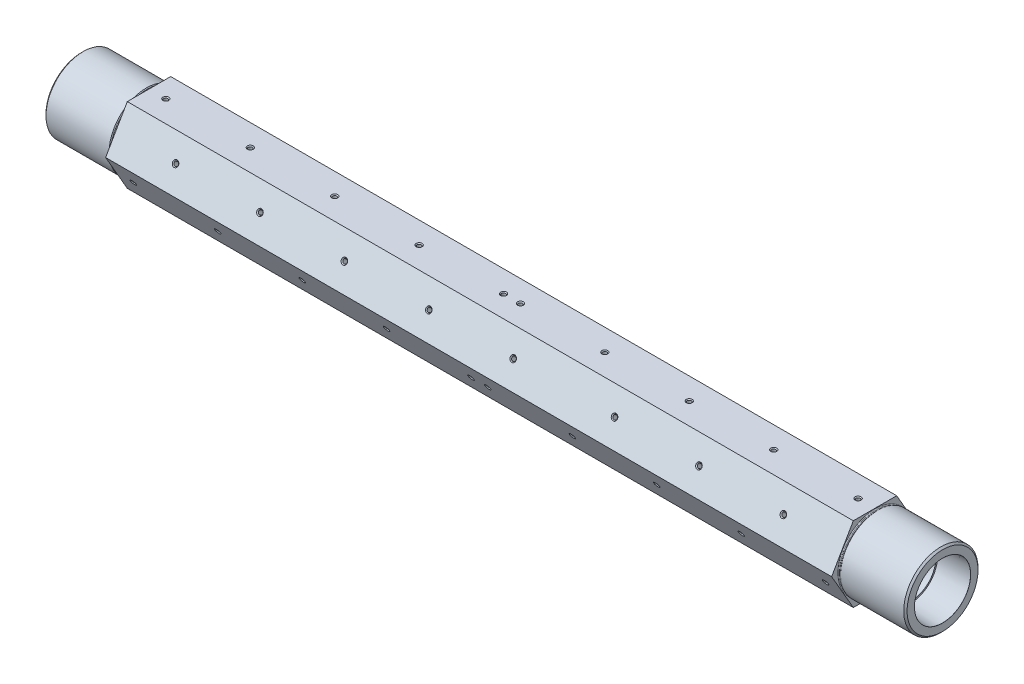
from build123d import *

# Parameters (mm, degrees)
EXTRUDE_1_DEPTH             = 430
HOLE_WIZARD_2_5_2_5_1_D     = 2.5
HOLE_WIZARD_2_5_2_5_1_DEPTH = 7
HOLE_WIZARD_2_5_2_5_1_TIP   = 0.751075774
HOLE_WIZARD_2_5_2_5_2_D     = 2.5
HOLE_WIZARD_2_5_2_5_2_DEPTH = 7
HOLE_WIZARD_2_5_2_5_2_TIP   = 0.751075774
HOLE_WIZARD_2_5_2_5_3_D     = 2.5
HOLE_WIZARD_2_5_2_5_3_DEPTH = 7
HOLE_WIZARD_2_5_2_5_3_TIP   = 0.751075774
HOLE_WIZARD_2_5_2_5_4_D     = 2.5
HOLE_WIZARD_2_5_2_5_4_DEPTH = 7
HOLE_WIZARD_2_5_2_5_4_TIP   = 0.751075774
HOLE_WIZARD_2_5_2_5_5_D     = 2.5
HOLE_WIZARD_2_5_2_5_5_DEPTH = 7
HOLE_WIZARD_2_5_2_5_5_TIP   = 0.751075774
HOLE_WIZARD_2_5_2_5_6_D     = 2.5
HOLE_WIZARD_2_5_2_5_6_DEPTH = 7
HOLE_WIZARD_2_5_2_5_6_TIP   = 0.751075774
CHAMFER_1_SIZE              = 0.5
CHAMFER_2_SIZE              = 1
CHAMFER_3_SIZE2             = 0.025012178
CHAMFER_3_SIZE              = 0.024219584
CHAMFER_3_EDGE_2_SIZE2      = 0.025012178
CHAMFER_3_EDGE_2_SIZE       = 0.024219584
FILLET_1_R                  = 0.3
FILLET_2_R                  = 0.5


with BuildPart() as part:
    # Эскиз1 → Бобышка-Вытянуть1 (new body)
    with BuildSketch(Plane(origin=(470, 0, 0), x_dir=(0, 0, -1), z_dir=(1, 0, 0))):
        Polygon((-12.846043489, -22.25), (12.846043489, -22.25), (25.692086979, 0), (12.846043489, 22.25), (-12.846043489, 22.25), (-25.692086979, 0), align=None)
    extrude(amount=-EXTRUDE_1_DEPTH)

    # Эскиз2 → Повернуть1 (revolve)
    with BuildSketch(Plane.XY):
        Polygon((0, 22), (0, 0), (40, 0), (40, 21.5), (38.875735931, 21.5), (38.375735931, 22), align=None)
    revolve(axis=Axis((0, 0, 0), (1, 0, 0)))

    # Эскиз3 → Повернуть2 (revolve)
    with BuildSketch(Plane.XY):
        Polygon((470, 21.5), (470, 0), (510, 0), (510, 22), (471.624264069, 22), (471.124264069, 21.5), align=None)
    revolve(axis=Axis((470, 0, 0), (1, 0, 0)))

    # Эскиз4 → Вырез-Повернуть1 (revolve, cut)
    with BuildSketch(Plane.XY):
        Polygon((0, 16.625280416), (0, 0), (510, 0), (510, 16.625280416), (491, 16.032164615), (491, 15.1455), (474, 15.1455), (474, 12), (36, 12), (36, 15.145), (19, 15.145), (19, 16.032164615), align=None)
    revolve(axis=Axis((0, 0, 0), (1, 0, 0)), mode=Mode.SUBTRACT)

    # Диаметр отверстия Ø2.5 (2.5)1
    with Locations(Plane(origin=(0, 11.125, 19.269065234), x_dir=(1, 0, 0), z_dir=(0, 0.5, 0.866025404))):
        with Locations((75, 0), (125, 0), (175, 0), (225, 0), (275, 0), (335, 0), (385, 0), (435, 0)):
            Hole(HOLE_WIZARD_2_5_2_5_1_D / 2, depth=HOLE_WIZARD_2_5_2_5_1_DEPTH)
            with Locations((0, 0, -(HOLE_WIZARD_2_5_2_5_1_DEPTH + HOLE_WIZARD_2_5_2_5_1_TIP / 2))):  # 118° drill point
                Cone(0, HOLE_WIZARD_2_5_2_5_1_D / 2, HOLE_WIZARD_2_5_2_5_1_TIP, mode=Mode.SUBTRACT)

    # Диаметр отверстия Ø2.5 (2.5)2
    with Locations(Plane(origin=(0, -22.25, 0), x_dir=(-1, 0, 0), z_dir=(0, -1, 0))):
        with Locations((-75, 0), (-125, 0), (-175, 0), (-225, 0), (-275, 0), (-335, 0), (-385, 0), (-435, 0)):
            Hole(HOLE_WIZARD_2_5_2_5_2_D / 2, depth=HOLE_WIZARD_2_5_2_5_2_DEPTH)
            with Locations((0, 0, -(HOLE_WIZARD_2_5_2_5_2_DEPTH + HOLE_WIZARD_2_5_2_5_2_TIP / 2))):  # 118° drill point
                Cone(0, HOLE_WIZARD_2_5_2_5_2_D / 2, HOLE_WIZARD_2_5_2_5_2_TIP, mode=Mode.SUBTRACT)

    # Диаметр отверстия Ø2.5 (2.5)3
    with Locations(Plane(origin=(0, -11.125, 19.269065234), x_dir=(1, 0, 0), z_dir=(0, -0.5, 0.866025404))):
        with Locations((50, 0), (100, 0), (150, 0), (200, 0), (250, 0), (460, 0), (410, 0), (360, 0), (310, 0), (260, 0)):
            Hole(HOLE_WIZARD_2_5_2_5_3_D / 2, depth=HOLE_WIZARD_2_5_2_5_3_DEPTH)
            with Locations((0, 0, -(HOLE_WIZARD_2_5_2_5_3_DEPTH + HOLE_WIZARD_2_5_2_5_3_TIP / 2))):  # 118° drill point
                Cone(0, HOLE_WIZARD_2_5_2_5_3_D / 2, HOLE_WIZARD_2_5_2_5_3_TIP, mode=Mode.SUBTRACT)

    # Диаметр отверстия Ø2.5 (2.5)4
    with Locations(Plane(origin=(0, -11.125, -19.269065234), x_dir=(-1, 0, 0), z_dir=(0, -0.5, -0.866025404))):
        with Locations((-50, 0), (-100, 0), (-150, 0), (-200, 0), (-250, 0), (-460, 0), (-410, 0), (-360, 0), (-310, 0), (-260, 0)):
            Hole(HOLE_WIZARD_2_5_2_5_4_D / 2, depth=HOLE_WIZARD_2_5_2_5_4_DEPTH)
            with Locations((0, 0, -(HOLE_WIZARD_2_5_2_5_4_DEPTH + HOLE_WIZARD_2_5_2_5_4_TIP / 2))):  # 118° drill point
                Cone(0, HOLE_WIZARD_2_5_2_5_4_D / 2, HOLE_WIZARD_2_5_2_5_4_TIP, mode=Mode.SUBTRACT)

    # Диаметр отверстия Ø2.5 (2.5)5
    with Locations(Plane(origin=(0, 22.25, 0), x_dir=(1, 0, 0), z_dir=(0, 1, 0))):
        with Locations((260, 0), (310, 0), (360, 0), (50, 0), (100, 0), (150, 0), (200, 0), (250, 0), (460, 0), (410, 0)):
            Hole(HOLE_WIZARD_2_5_2_5_5_D / 2, depth=HOLE_WIZARD_2_5_2_5_5_DEPTH)
            with Locations((0, 0, -(HOLE_WIZARD_2_5_2_5_5_DEPTH + HOLE_WIZARD_2_5_2_5_5_TIP / 2))):  # 118° drill point
                Cone(0, HOLE_WIZARD_2_5_2_5_5_D / 2, HOLE_WIZARD_2_5_2_5_5_TIP, mode=Mode.SUBTRACT)

    # Диаметр отверстия Ø2.5 (2.5)6
    with Locations(Plane(origin=(0, 11.125, -19.269065234), x_dir=(-1, 0, 0), z_dir=(0, 0.5, -0.866025404))):
        with Locations((-435, 0), (-385, 0), (-335, 0), (-275, 0), (-225, 0), (-175, 0), (-75, 0), (-125, 0)):
            Hole(HOLE_WIZARD_2_5_2_5_6_D / 2, depth=HOLE_WIZARD_2_5_2_5_6_DEPTH)
            with Locations((0, 0, -(HOLE_WIZARD_2_5_2_5_6_DEPTH + HOLE_WIZARD_2_5_2_5_6_TIP / 2))):  # 118° drill point
                Cone(0, HOLE_WIZARD_2_5_2_5_6_D / 2, HOLE_WIZARD_2_5_2_5_6_TIP, mode=Mode.SUBTRACT)

    # Фаска1
    chamfer_1_edges = [part.edges().sort_by_distance(p)[0] for p in [
        (173.75, -22.25, 0),
        (123.75, -22.25, 0),
        (73.75, -22.25, 0),
        (261.25, -11.125, 19.269065234),
        (311.25, -11.125, 19.269065234),
        (361.25, -11.125, 19.269065234),
        (411.25, -11.125, 19.269065234),
        (461.25, -11.125, 19.269065234),
        (251.25, -11.125, 19.269065234),
        (201.25, -11.125, 19.269065234),
        (151.25, -11.125, 19.269065234),
        (101.25, -11.125, 19.269065234),
        (51.25, -11.125, 19.269065234),
        (258.75, -11.125, -19.269065234),
        (308.75, -11.125, -19.269065234),
        (358.75, -11.125, -19.269065234),
        (408.75, -11.125, -19.269065234),
        (458.75, -11.125, -19.269065234),
        (248.75, -11.125, -19.269065234),
        (198.75, -11.125, -19.269065234),
        (148.75, -11.125, -19.269065234),
        (98.75, -11.125, -19.269065234),
        (48.75, -11.125, -19.269065234),
        (411.25, 22.25, 0),
        (461.25, 22.25, 0),
        (251.25, 22.25, 0),
        (201.25, 22.25, 0),
        (151.25, 22.25, 0),
        (101.25, 22.25, 0),
        (51.25, 22.25, 0),
        (361.25, 22.25, 0),
        (311.25, 22.25, 0),
        (261.25, 22.25, 0),
        (123.75, 11.125, -19.269065234),
        (73.75, 11.125, -19.269065234),
        (173.75, 11.125, -19.269065234),
        (223.75, 11.125, -19.269065234),
        (273.75, 11.125, -19.269065234),
        (333.75, 11.125, -19.269065234),
        (383.75, 11.125, -19.269065234),
        (433.75, 11.125, -19.269065234),
        (436.25, 11.125, 19.269065234),
        (386.25, 11.125, 19.269065234),
        (336.25, 11.125, 19.269065234),
        (276.25, 11.125, 19.269065234),
        (226.25, 11.125, 19.269065234),
        (176.25, 11.125, 19.269065234),
        (126.25, 11.125, 19.269065234),
        (76.25, 11.125, 19.269065234),
        (433.75, -22.25, 0),
        (383.75, -22.25, 0),
        (333.75, -22.25, 0),
        (273.75, -22.25, 0),
        (223.75, -22.25, 0),
    ]]
    chamfer(chamfer_1_edges, length=CHAMFER_1_SIZE)

    # Фаска2
    chamfer_2_edges = [part.edges().sort_by_distance(p)[0] for p in [
        (0, -22, 0),
        (510, -22, 0),
    ]]
    chamfer(chamfer_2_edges, length=CHAMFER_2_SIZE)

    # Фаска3
    chamfer_3_edges = [part.edges().sort_by_distance(p)[0] for p in [
        (0, -16.625280416, 0),
    ]]
    chamfer(chamfer_3_edges, length=CHAMFER_3_SIZE, length2=CHAMFER_3_SIZE2)

    # Фаска3 edge 2
    chamfer_3_edge_2_edges = [part.edges().sort_by_distance(p)[0] for p in [
        (510, -16.625280416, 0),
    ]]
    chamfer(chamfer_3_edge_2_edges, length=CHAMFER_3_EDGE_2_SIZE, length2=CHAMFER_3_EDGE_2_SIZE2)

    # Скругление1
    fillet_1_edges = [part.edges().sort_by_distance(p)[0] for p in [
        (38.875735931, -21.5, 0),
        (471.124264069, -21.5, 0),
    ]]
    fillet(fillet_1_edges, radius=FILLET_1_R)

    # Скругление2
    fillet_2_edges = [part.edges().sort_by_distance(p)[0] for p in [
        (40, -21.5, 0),
        (470, -21.5, 0),
    ]]
    fillet(fillet_2_edges, radius=FILLET_2_R)


solid = part.part
